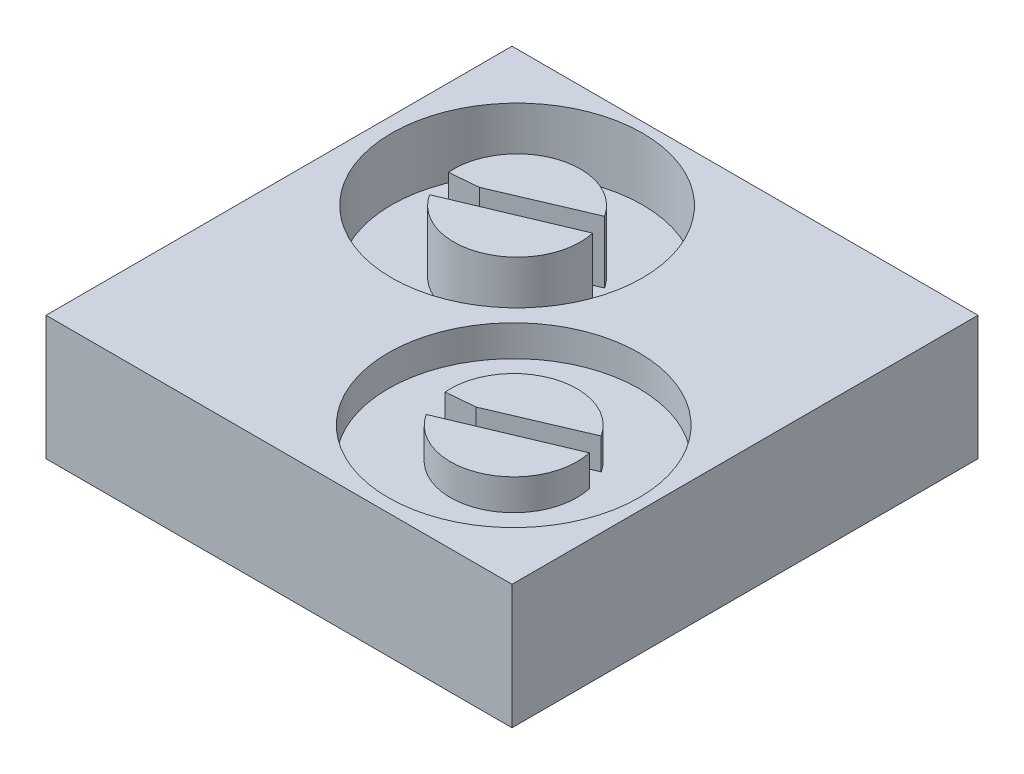
from build123d import *

# Parameters (mm, degrees)
SKETCH1_W           = 15
SKETCH1_H           = 15
BOSS_EXTRUDE1_DEPTH = 4
SKETCH3_R           = 4.037394367
CUT_EXTRUDE2_DEPTH  = 1
SKETCH2_R           = 4.037394367
CUT_EXTRUDE3_DEPTH  = 2


with BuildPart() as part:
    # Sketch1 → Boss-Extrude1 (new body)
    with BuildSketch(Plane(origin=(0, 0, 0), x_dir=(1, 0, 0), z_dir=(0, 1, 0))):
        with Locations((-3.092315207, 3.037793064)):
            Rectangle(SKETCH1_W, SKETCH1_H)
    extrude(amount=BOSS_EXTRUDE1_DEPTH)

    # Sketch3 → Cut-Extrude2 (cut)
    with BuildSketch(Plane(origin=(0, 4, 0), x_dir=(1, 0, 0), z_dir=(0, 1, 0))):
        Circle(SKETCH3_R)
        with BuildLine():
            Line((-2.029498636, -0.179195686), (-1.109423018, -0.097957109))
            Line((-1.109423018, -0.097957109), (1.710275386, 1.107218999))
            ThreePointArc((1.710275386, 1.107218999), (-0.662715291, 1.926599141), (-2.029498636, -0.179195686))
        make_face(mode=Mode.SUBTRACT)
        with BuildLine():
            Line((1.987822429, 0.44669654), (-0.18326754, -0.467866029))
            Line((-0.18326754, -0.467866029), (-1.709632143, -1.108211957))
            ThreePointArc((-1.709632143, -1.108211957), (0.789799068, -1.87808233), (1.987822429, 0.44669654))
        make_face(mode=Mode.SUBTRACT)
    extrude(amount=-CUT_EXTRUDE2_DEPTH, mode=Mode.SUBTRACT)

    # Sketch2 → Cut-Extrude3 (cut)
    with BuildSketch(Plane(origin=(0, 4, 0), x_dir=(1, 0, 0), z_dir=(0, 1, 0))):
        with Locations((-6.070431837, 6.178975723)):
            Circle(SKETCH2_R)
        with BuildLine():
            Line((-8.099930473, 5.999780036), (-7.179854855, 6.081018614))
            Line((-7.179854855, 6.081018614), (-4.360156451, 7.286194722))
            ThreePointArc((-4.360156451, 7.286194722), (-6.733147128, 8.105574864), (-8.099930473, 5.999780036))
        make_face(mode=Mode.SUBTRACT)
        with BuildLine():
            Line((-4.082609408, 6.625672263), (-6.253699377, 5.711109693))
            Line((-6.253699377, 5.711109693), (-7.78006398, 5.070763766))
            ThreePointArc((-7.78006398, 5.070763766), (-5.280632769, 4.300893392), (-4.082609408, 6.625672263))
        make_face(mode=Mode.SUBTRACT)
    extrude(amount=-CUT_EXTRUDE3_DEPTH, mode=Mode.SUBTRACT)


solid = part.part
